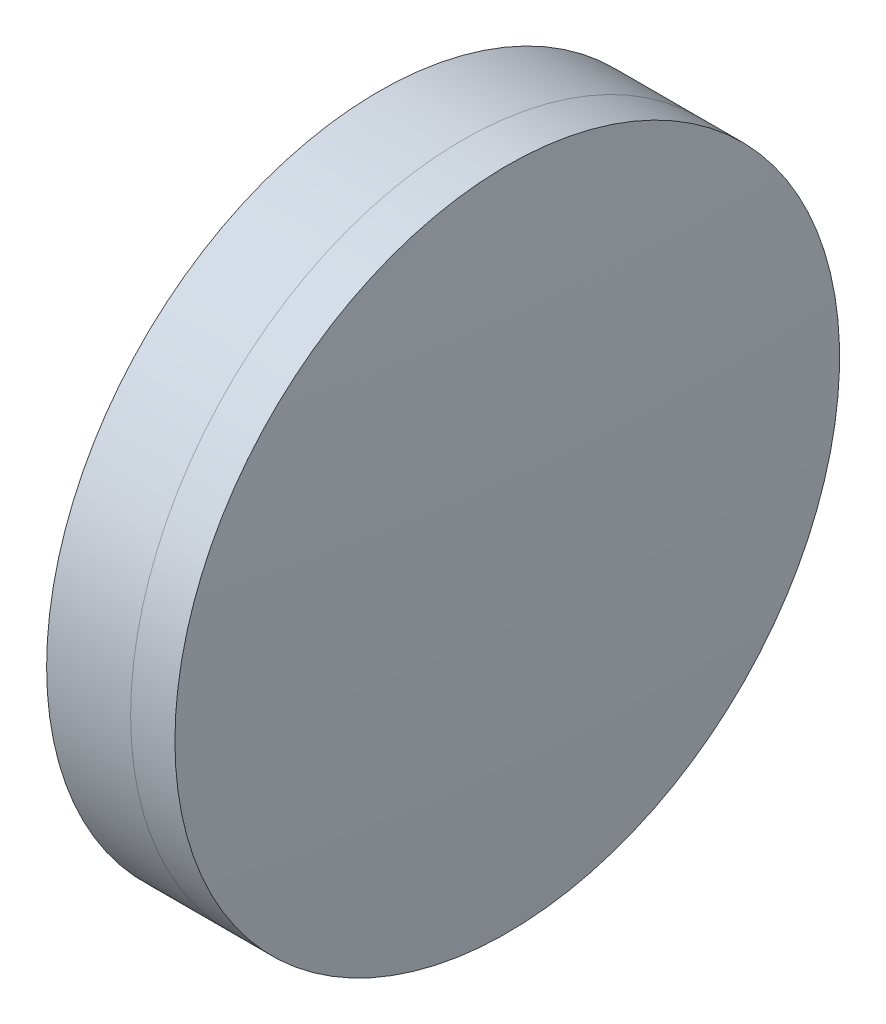
from build123d import *


with BuildPart() as part:
    # 草图1 one side → 旋转1 (revolve)
    with BuildSketch(Plane(origin=(0, 0, 0), x_dir=(1, 0, 0), z_dir=(0, 1, 0)), mode=Mode.PRIVATE) as revolve_1_sk:
        with BuildLine():
            ThreePointArc((529.195435731, 15), (527.556963789, 7.579403063), (527.006965225, 0))
            Line((527.006965225, 0), (533.506965225, 0))
            ThreePointArc((533.506965225, 0), (533.376741577, 7.504518103), (532.986227435, 15))
            Line((532.986227435, 15), (529.195435731, 15))
        make_face()
    revolve(revolve_1_sk.sketch.rotate(Axis((124.523309526, 0, 0), (1, 0, 0)), 180), axis=Axis((124.523309526, 0, 0), (1, 0, 0)))  # turned: the seam where the file's is


with BuildPart() as body_2:
    # 草图2 one side → 旋转3 (revolve)
    with BuildSketch(Plane(origin=(0, 0, 0), x_dir=(1, 0, 0), z_dir=(0, 1, 0)), mode=Mode.PRIVATE) as revolve_3_sk:
        with BuildLine():
            Line((534.986227435, 15), (532.986227435, 15))
            ThreePointArc((532.986227435, 15), (533.376741577, 7.504518103), (533.506965225, 0))
            Line((533.506965225, 0), (535.506965225, 0))
            ThreePointArc((535.506965225, 0), (535.376741577, 7.504518103), (534.986227435, 15))
        make_face()
    revolve(revolve_3_sk.sketch.rotate(Axis((-0.551919993, 0, 0), (1, 0, 0)), 180), axis=Axis((-0.551919993, 0, 0), (1, 0, 0)))  # turned: the seam where the file's is


solid = Compound([part.part, body_2.part])
